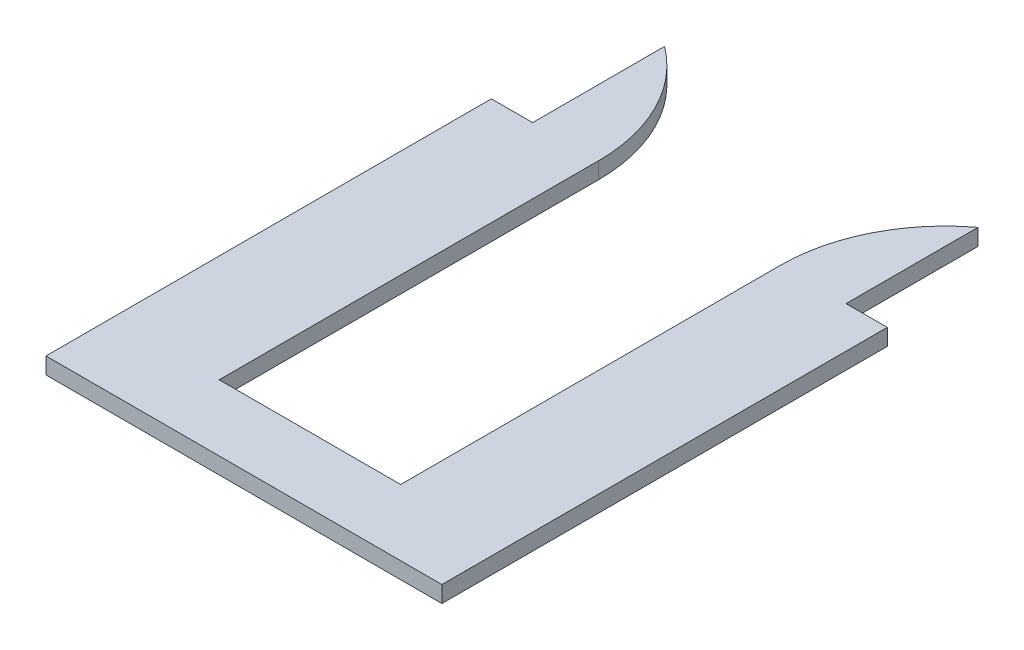
from build123d import *

# Parameters (mm, degrees)
BOSS_EXTRUDE1_DEPTH = 12.7


with BuildPart() as part:
    # Sketch2 → Boss-Extrude1 (new body)
    with BuildSketch(Plane(origin=(0, 0, 0), x_dir=(1, 0, 0), z_dir=(0, 1, 0))):
        with BuildLine():
            Line((0, 0), (304.8, 0))
            Line((304.8, 0), (304.8, 342.9))
            Line((304.8, 342.9), (273.05, 342.9))
            Line((273.05, 342.9), (273.05, 444.5))
            ThreePointArc((273.05, 444.5), (235.657746743, 399.696126628), (222.25, 342.9))
            Line((222.25, 342.9), (222.25, 50.8))
            Line((222.25, 50.8), (82.55, 50.8))
            Line((82.55, 50.8), (82.55, 342.9))
            ThreePointArc((82.55, 342.9), (69.142253257, 399.696126628), (31.75, 444.5))
            Line((31.75, 444.5), (31.75, 342.9))
            Line((31.75, 342.9), (0, 342.9))
            Line((0, 342.9), (0, 0))
        make_face()
    extrude(amount=BOSS_EXTRUDE1_DEPTH)


solid = part.part
